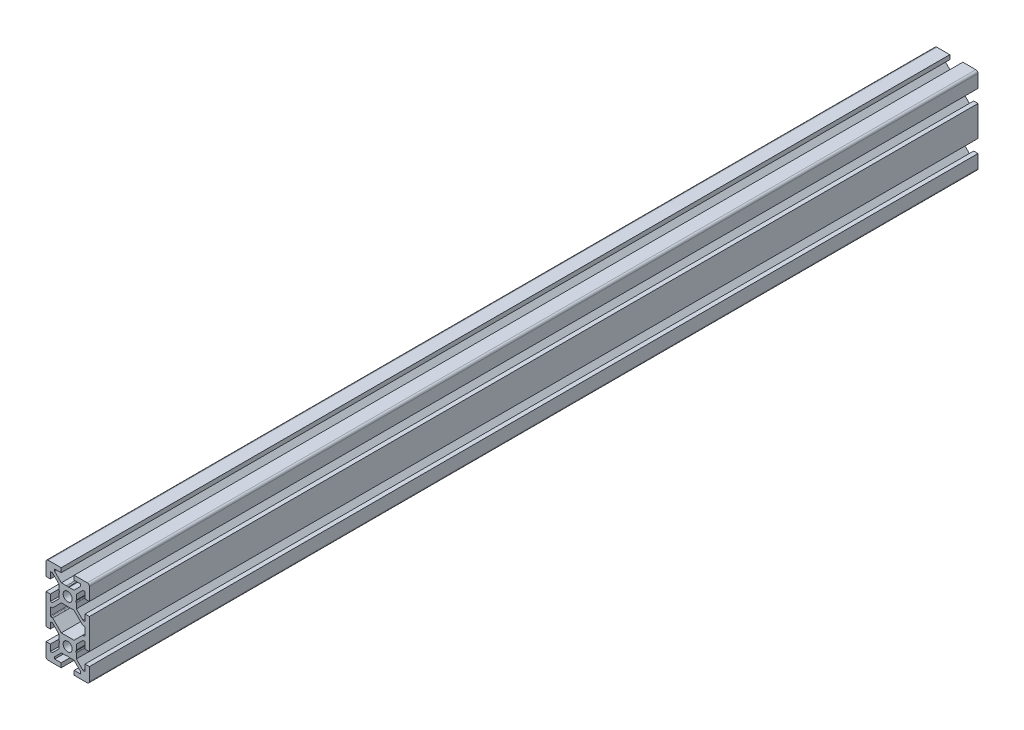
from build123d import *

# Parameters (mm, degrees)
BOSS_EXTRUDE1_DEPTH = 410
SKETCH2_W           = 1200
SKETCH2_H           = 2.1
SKETCH3_W           = 1200
SKETCH3_H           = 2.1


with BuildPart() as part:
    # Sketch1 → Boss-Extrude1 (new body)
    with BuildSketch(Plane.XY):
        with BuildLine():
            Line((-9, -20), (-3, -20))
            Line((-3, -20), (-3, -18))
            Line((-3, -18), (-6, -18))
            Line((-6, -18), (-6, -17.060660172))
            Line((-6, -17.060660172), (-2.939339828, -14))
            Line((-2.939339828, -14), (-2.5, -14))
            Line((-2.5, -14), (-0.653589838, -14))
            ThreePointArc((-0.653589838, -14), (-0.524180316, -13.982962913), (-0.403589838, -13.933012702))
            Line((-0.403589838, -13.933012702), (0, -13.7))
            Line((0, -13.7), (0.403589838, -13.933012702))
            ThreePointArc((0.403589838, -13.933012702), (0.524180316, -13.982962913), (0.653589838, -14))
            Line((0.653589838, -14), (2.939339828, -14))
            Line((2.939339828, -14), (6, -17.060660172))
            Line((6, -17.060660172), (6, -18))
            Line((6, -18), (3, -18))
            Line((3, -18), (3, -20))
            Line((3, -20), (9, -20))
            ThreePointArc((9, -20), (9.707106781, -19.707106781), (10, -19))
            Line((10, -19), (10, -13))
            Line((10, -13), (8, -13))
            Line((8, -13), (8, -16))
            Line((8, -16), (7.060660172, -16))
            Line((7.060660172, -16), (4, -12.939339828))
            Line((4, -12.939339828), (4, -12.5))
            Line((4, -12.5), (4, -10.653589838))
            ThreePointArc((4, -10.653589838), (3.982962913, -10.524180316), (3.933012702, -10.403589838))
            Line((3.933012702, -10.403589838), (3.7, -10))
            Line((3.7, -10), (3.933012702, -9.596410162))
            ThreePointArc((3.933012702, -9.596410162), (3.982962913, -9.475819684), (4, -9.346410162))
            Line((4, -9.346410162), (4, -7.060660172))
            Line((4, -7.060660172), (7.060660172, -4))
            Line((7.060660172, -4), (8, -4))
            Line((8, -4), (8, -7))
            Line((8, -7), (10, -7))
            Line((10, -7), (10, 7))
            Line((10, 7), (8, 7))
            Line((8, 7), (8, 4))
            Line((8, 4), (7.060660172, 4))
            Line((7.060660172, 4), (4, 7.060660172))
            Line((4, 7.060660172), (4, 9.346410162))
            ThreePointArc((4, 9.346410162), (3.982962913, 9.475819684), (3.933012702, 9.596410162))
            Line((3.933012702, 9.596410162), (3.7, 10))
            Line((3.7, 10), (3.933012702, 10.403589838))
            ThreePointArc((3.933012702, 10.403589838), (3.982962913, 10.524180316), (4, 10.653589838))
            Line((4, 10.653589838), (4, 12.5))
            Line((4, 12.5), (4, 12.939339828))
            Line((4, 12.939339828), (7.060660172, 16))
            Line((7.060660172, 16), (8, 16))
            Line((8, 16), (8, 13))
            Line((8, 13), (10, 13))
            Line((10, 13), (10, 19))
            ThreePointArc((10, 19), (9.707106781, 19.707106781), (9, 20))
            Line((9, 20), (3, 20))
            Line((3, 20), (3, 18))
            Line((3, 18), (6, 18))
            Line((6, 18), (6, 17.060660172))
            Line((6, 17.060660172), (2.939339828, 14))
            Line((2.939339828, 14), (0.653589838, 14))
            ThreePointArc((0.653589838, 14), (0.524180316, 13.982962913), (0.403589838, 13.933012702))
            Line((0.403589838, 13.933012702), (0, 13.7))
            Line((0, 13.7), (-0.403589838, 13.933012702))
            ThreePointArc((-0.403589838, 13.933012702), (-0.524180316, 13.982962913), (-0.653589838, 14))
            Line((-0.653589838, 14), (-2.5, 14))
            Line((-2.5, 14), (-2.939339828, 14))
            Line((-2.939339828, 14), (-6, 17.060660172))
            Line((-6, 17.060660172), (-6, 18))
            Line((-6, 18), (-3, 18))
            Line((-3, 18), (-3, 20))
            Line((-3, 20), (-9, 20))
            ThreePointArc((-9, 20), (-9.707106781, 19.707106781), (-10, 19))
            Line((-10, 19), (-10, 13))
            Line((-10, 13), (-8, 13))
            Line((-8, 13), (-8, 16))
            Line((-8, 16), (-7.060660172, 16))
            Line((-7.060660172, 16), (-4, 12.939339828))
            Line((-4, 12.939339828), (-4, 10.653589838))
            ThreePointArc((-4, 10.653589838), (-3.982962913, 10.524180316), (-3.933012702, 10.403589838))
            Line((-3.933012702, 10.403589838), (-3.7, 10))
            Line((-3.7, 10), (-3.933012702, 9.596410162))
            ThreePointArc((-3.933012702, 9.596410162), (-3.982962913, 9.475819684), (-4, 9.346410162))
            Line((-4, 9.346410162), (-4, 7.5))
            Line((-4, 7.5), (-4, 7.060660172))
            Line((-4, 7.060660172), (-7.060660172, 4))
            Line((-7.060660172, 4), (-8, 4))
            Line((-8, 4), (-8, 7))
            Line((-8, 7), (-10, 7))
            Line((-10, 7), (-10, -7))
            Line((-10, -7), (-8, -7))
            Line((-8, -7), (-8, -4))
            Line((-8, -4), (-7.060660172, -4))
            Line((-7.060660172, -4), (-4, -7.060660172))
            Line((-4, -7.060660172), (-4, -7.5))
            Line((-4, -7.5), (-4, -9.346410162))
            ThreePointArc((-4, -9.346410162), (-3.982962913, -9.475819684), (-3.933012702, -9.596410162))
            Line((-3.933012702, -9.596410162), (-3.7, -10))
            Line((-3.7, -10), (-3.933012702, -10.403589838))
            ThreePointArc((-3.933012702, -10.403589838), (-3.982962913, -10.524180316), (-4, -10.653589838))
            Line((-4, -10.653589838), (-4, -12.939339828))
            Line((-4, -12.939339828), (-7.060660172, -16))
            Line((-7.060660172, -16), (-8, -16))
            Line((-8, -16), (-8, -13))
            Line((-8, -13), (-10, -13))
            Line((-10, -13), (-10, -19))
            ThreePointArc((-10, -19), (-9.707106781, -19.707106781), (-9, -20))
        make_face()
        with BuildLine():
            Line((-7.7, -2), (-7.063603897, -2))
            ThreePointArc((-7.063603897, -2), (-6.948798867, -2.02283614), (-6.851471863, -2.087867966))
            Line((-6.851471863, -2.087867966), (-2.939339828, -6))
            Line((-2.939339828, -6), (2.939339828, -6))
            Line((2.939339828, -6), (6.851471863, -2.087867966))
            ThreePointArc((6.851471863, -2.087867966), (6.948798867, -2.02283614), (7.063603897, -2))
            Line((7.063603897, -2), (7.7, -2))
            ThreePointArc((7.7, -2), (7.912132034, -1.912132034), (8, -1.7))
            Line((8, -1.7), (8, 1.7))
            ThreePointArc((8, 1.7), (7.912132034, 1.912132034), (7.7, 2))
            Line((7.7, 2), (7.063603897, 2))
            ThreePointArc((7.063603897, 2), (6.948798867, 2.02283614), (6.851471863, 2.087867966))
            Line((6.851471863, 2.087867966), (2.939339828, 6))
            Line((2.939339828, 6), (-2.939339828, 6))
            Line((-2.939339828, 6), (-6.851471863, 2.087867966))
            ThreePointArc((-6.851471863, 2.087867966), (-6.948798867, 2.02283614), (-7.063603897, 2))
            Line((-7.063603897, 2), (-7.7, 2))
            ThreePointArc((-7.7, 2), (-7.912132034, 1.912132034), (-8, 1.7))
            Line((-8, 1.7), (-8, -1.7))
            ThreePointArc((-8, -1.7), (-7.912132034, -1.912132034), (-7.7, -2))
        make_face(mode=Mode.SUBTRACT)
    extrude(amount=-BOSS_EXTRUDE1_DEPTH)

    # Sketch2 → Cut-Revolve1 (revolve, cut)
    with BuildSketch(Plane(origin=(0, 0, 0), x_dir=(0, 0, -1), z_dir=(1, 0, 0))):
        with Locations((600, 11.05)):
            Rectangle(SKETCH2_W, SKETCH2_H)
    revolve(axis=Axis((0, 10, -1200), (0, 0, 1)), mode=Mode.SUBTRACT)

    # Sketch3 → Cut-Revolve2 (revolve, cut)
    with BuildSketch(Plane(origin=(0, 0, 0), x_dir=(0, 0, -1), z_dir=(1, 0, 0))):
        with Locations((600, -8.95)):
            Rectangle(SKETCH3_W, SKETCH3_H)
    revolve(axis=Axis((0, -10, -1200), (0, 0, 1)), mode=Mode.SUBTRACT)


solid = part.part
